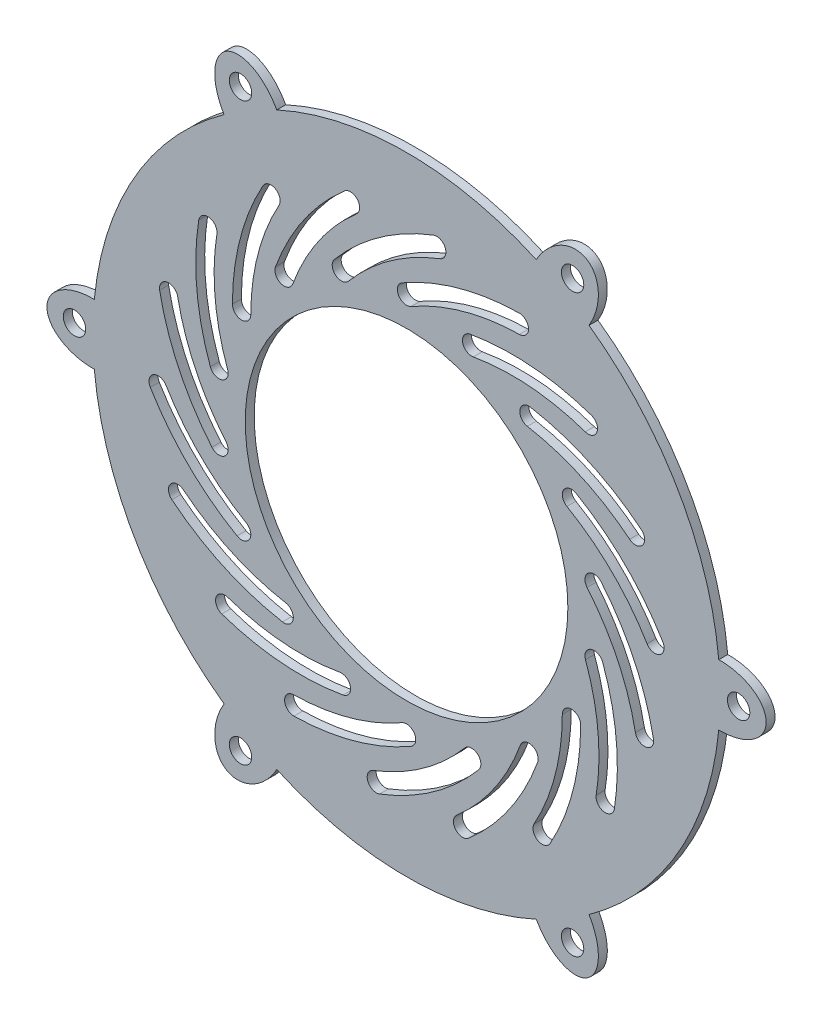
from build123d import *

# Parameters (mm, degrees)
SKETCH1_R           = 36
BOSS_EXTRUDE1_DEPTH = 2
CUT_EXTRUDE3_DEPTH  = 3.0000001
SKETCH6_R           = 2.5
CUT_EXTRUDE4_DEPTH  = 3.0000001
CIRPATTERN1_COUNT   = 6


with BuildPart() as part:
    # Sketch1 → Boss-Extrude1 (new body)
    with BuildSketch(Plane.XY):
        with BuildLine():
            ThreePointArc((-69.673793495, -6.75), (-60.632475945, -34.981464531), (-40.717391873, -56.939388819))
            add(Edge.make_bspline(
                [(-40.717391873, -56.939388819), (-46.197723193, -65.978636893), (-40.119018626, -69.488178611), (-34.04031406, -72.997720328), (-28.952261257, -63.731990147)],
                knots=[1.538524104, 1.538524104, 1.538524104, 3.141592654, 3.141592654, 4.744661203, 4.744661203, 4.744661203], degree=2, weights=[1, 0.695605268, 1, 0.695605268, 1]))
            ThreePointArc((-28.952261257, -63.731990147), (0, -70), (28.952261257, -63.731990147))
            add(Edge.make_bspline(
                [(28.952261257, -63.731990147), (34.04031406, -72.997720328), (40.119018626, -69.488178611), (46.197723193, -65.978636893), (40.717391873, -56.939388819)],
                knots=[1.538524104, 1.538524104, 1.538524104, 3.141592654, 3.141592654, 4.744661203, 4.744661203, 4.744661203], degree=2, weights=[1, 0.695605268, 1, 0.695605268, 1]))
            ThreePointArc((40.717391873, -56.939388819), (60.621778265, -35), (69.66965313, -6.792601328))
            add(Edge.make_bspline(
                [(69.66965313, -6.792601328), (80.238037253, -7.019083435), (80.238037253, 0), (80.238037253, 7.019083435), (69.66965313, 6.792601328)],
                knots=[1.538524104, 1.538524104, 1.538524104, 3.141592654, 3.141592654, 4.744661203, 4.744661203, 4.744661203], degree=2, weights=[1, 0.695605268, 1, 0.695605268, 1]))
            ThreePointArc((69.66965313, 6.792601328), (60.621778265, 35), (40.717391873, 56.939388819))
            add(Edge.make_bspline(
                [(40.717391873, 56.939388819), (46.197723193, 65.978636893), (40.119018626, 69.488178611), (34.04031406, 72.997720328), (28.952261257, 63.731990147)],
                knots=[4.680116758, 4.680116758, 4.680116758, 6.283185307, 6.283185307, 7.886253857, 7.886253857, 7.886253857], degree=2, weights=[1, 0.695605268, 1, 0.695605268, 1]))
            ThreePointArc((28.952261257, 63.731990147), (0, 70), (-28.952261257, 63.731990147))
            add(Edge.make_bspline(
                [(-28.952261257, 63.731990147), (-34.04031406, 72.997720328), (-40.119018626, 69.488178611), (-46.197723193, 65.978636893), (-40.717391873, 56.939388819)],
                knots=[4.680116758, 4.680116758, 4.680116758, 6.283185307, 6.283185307, 7.886253857, 7.886253857, 7.886253857], degree=2, weights=[1, 0.695605268, 1, 0.695605268, 1]))
            ThreePointArc((-40.717391873, 56.939388819), (-60.632475945, 34.981464531), (-69.673793495, 6.75))
            add(Edge.make_bspline(
                [(-69.673793495, 6.75), (-80.25, 6.971880263), (-80.25, 0), (-80.25, -6.971880263), (-69.673793495, -6.75)],
                knots=[1.538965927, 1.538965927, 1.538965927, 3.141592654, 3.141592654, 4.74421938, 4.74421938, 4.74421938], degree=2, weights=[1, 0.69576396, 1, 0.69576396, 1]))
        make_face()
        Circle(SKETCH1_R, mode=Mode.SUBTRACT)
    extrude(amount=BOSS_EXTRUDE1_DEPTH)

    # Sketch2 → Cut-Extrude3 (cut, through all)
    with BuildSketch(Plane.XY):
        with BuildLine():
            ThreePointArc((25.132341942, 51.516012736), (11.592230809, 49.56266401), (-1.025, 44.275352078))
            ThreePointArc((-1.025, 44.275352078), (-1.775352078, 41.475), (1.025, 40.724647922))
            ThreePointArc((1.025, 40.724647922), (12.686026625, 45.611257841), (25.199992553, 47.416570897))
            ThreePointArc((25.199992553, 47.416570897), (27.215888167, 49.500117122), (25.132341942, 51.516012736))
        make_face()
        with BuildLine():
            ThreePointArc((41.236190326, 39.813449827), (27.844563198, 42.608893194), (14.179877327, 41.955792277))
            ThreePointArc((14.179877327, 41.955792277), (12.517000198, 39.580957619), (14.891834856, 37.91808049))
            ThreePointArc((14.891834856, 37.91808049), (27.520934551, 38.521685773), (39.89766942, 35.93809671))
            ThreePointArc((39.89766942, 35.93809671), (42.504606431, 37.206512816), (41.236190326, 39.813449827))
        make_face()
        with BuildLine():
            ThreePointArc((52.366345575, 23.308797286), (40.738430323, 30.515861019), (27.674452176, 34.575744726))
            ThreePointArc((27.674452176, 34.575744726), (25.299617518, 32.912867597), (26.962494647, 30.538032939))
            ThreePointArc((26.962494647, 30.538032939), (39.036411604, 26.785829882), (49.783098528, 20.12495767))
            ThreePointArc((49.783098528, 20.12495767), (52.666641859, 20.425253955), (52.366345575, 23.308797286))
        make_face()
        with BuildLine():
            ThreePointArc((57.180346702, 3.99275979), (48.718641516, 14.742165638), (37.831079661, 23.025352078))
            ThreePointArc((37.831079661, 23.025352078), (35.030727583, 22.275), (35.781079661, 19.474647922))
            ThreePointArc((35.781079661, 19.474647922), (45.843521302, 11.81920759), (53.663951233, 1.884451723))
            ThreePointArc((53.663951233, 1.884451723), (56.476303001, 1.180408022), (57.180346702, 3.99275979))
        make_face()
        with BuildLine():
            ThreePointArc((55.097554126, -15.804863464), (50.822665532, -2.809652489), (43.424720611, 8.697762151))
            ThreePointArc((43.424720611, 8.697762151), (40.536614903, 8.950438659), (40.283938395, 6.062332951))
            ThreePointArc((40.283938395, 6.062332951), (47.121225752, -4.57298557), (51.072139424, -16.583346914))
            ThreePointArc((51.072139424, -16.583346914), (53.4740885, -18.20681254), (55.097554126, -15.804863464))
        make_face()
        with BuildLine():
            ThreePointArc((46.369183368, -33.696186928), (46.796726022, -20.022585061), (43.780699376, -6.678906257))
            ThreePointArc((43.780699376, -6.678906257), (41.153188209, -5.453677678), (39.92795963, -8.081188845))
            ThreePointArc((39.92795963, -8.081188845), (42.715414941, -20.413609181), (42.320273856, -33.050949169))
            ThreePointArc((42.320273856, -33.050949169), (44.022109733, -35.398022805), (46.369183368, -33.696186928))
        make_face()
        with BuildLine():
            ThreePointArc((32.04800476, -47.523252947), (37.126410708, -34.820498372), (38.856079661, -21.25))
            ThreePointArc((38.856079661, -21.25), (36.806079661, -19.2), (34.756079661, -21.25))
            ThreePointArc((34.756079661, -21.25), (33.157494676, -33.792050251), (28.463958681, -45.532119174))
            ThreePointArc((28.463958681, -45.532119174), (29.260414834, -48.3197091), (32.04800476, -47.523252947))
        make_face()
        with BuildLine():
            ThreePointArc((13.8613638, -55.618313291), (22.978102334, -45.418545683), (29.244843284, -33.258030126))
            ThreePointArc((29.244843284, -33.258030126), (28.019614705, -30.63051896), (25.392103539, -31.855747539))
            ThreePointArc((25.392103539, -31.855747539), (19.600291201, -43.094671344), (11.174470005, -52.521443624))
            ThreePointArc((11.174470005, -52.521443624), (10.969482069, -55.413325355), (13.8613638, -55.618313291))
        make_face()
        with BuildLine():
            ThreePointArc((-5.997162206, -57.004984214), (6.058295699, -50.538446079), (16.1062472, -41.254650983))
            ThreePointArc((16.1062472, -41.254650983), (15.853570691, -38.366545275), (12.965464983, -38.619221784))
            ThreePointArc((12.965464983, -38.619221784), (3.679003337, -47.199439063), (-7.462824671, -53.175906839))
            ThreePointArc((-7.462824671, -53.175906839), (-8.644532126, -55.823276759), (-5.997162206, -57.004984214))
        make_face()
        with BuildLine():
            ThreePointArc((-25.132341942, -51.516012736), (-11.592230809, -49.56266401), (1.025, -44.275352078))
            ThreePointArc((1.025, -44.275352078), (1.775352078, -41.475), (-1.025, -40.724647922))
            ThreePointArc((-1.025, -40.724647922), (-12.686026625, -45.611257841), (-25.199992553, -47.416570897))
            ThreePointArc((-25.199992553, -47.416570897), (-27.215888167, -49.500117122), (-25.132341942, -51.516012736))
        make_face()
        with BuildLine():
            ThreePointArc((-41.236190326, -39.813449827), (-27.844563198, -42.608893194), (-14.179877327, -41.955792277))
            ThreePointArc((-14.179877327, -41.955792277), (-12.517000198, -39.580957619), (-14.891834856, -37.91808049))
            ThreePointArc((-14.891834856, -37.91808049), (-27.520934551, -38.521685773), (-39.89766942, -35.93809671))
            ThreePointArc((-39.89766942, -35.93809671), (-42.504606431, -37.206512816), (-41.236190326, -39.813449827))
        make_face()
        with BuildLine():
            ThreePointArc((-52.366345575, -23.308797286), (-40.738430323, -30.515861019), (-27.674452176, -34.575744726))
            ThreePointArc((-27.674452176, -34.575744726), (-25.299617518, -32.912867597), (-26.962494647, -30.538032939))
            ThreePointArc((-26.962494647, -30.538032939), (-39.036411604, -26.785829882), (-49.783098528, -20.12495767))
            ThreePointArc((-49.783098528, -20.12495767), (-52.666641859, -20.425253955), (-52.366345575, -23.308797286))
        make_face()
        with BuildLine():
            ThreePointArc((-57.180346702, -3.99275979), (-48.718641516, -14.742165638), (-37.831079661, -23.025352078))
            ThreePointArc((-37.831079661, -23.025352078), (-35.030727583, -22.275), (-35.781079661, -19.474647922))
            ThreePointArc((-35.781079661, -19.474647922), (-45.843521302, -11.81920759), (-53.663951233, -1.884451723))
            ThreePointArc((-53.663951233, -1.884451723), (-56.476303001, -1.180408022), (-57.180346702, -3.99275979))
        make_face()
        with BuildLine():
            ThreePointArc((-55.097554126, 15.804863464), (-50.822665532, 2.809652489), (-43.424720611, -8.697762151))
            ThreePointArc((-43.424720611, -8.697762151), (-40.536614903, -8.950438659), (-40.283938395, -6.062332951))
            ThreePointArc((-40.283938395, -6.062332951), (-47.121225752, 4.57298557), (-51.072139424, 16.583346914))
            ThreePointArc((-51.072139424, 16.583346914), (-53.4740885, 18.20681254), (-55.097554126, 15.804863464))
        make_face()
        with BuildLine():
            ThreePointArc((-46.369183368, 33.696186928), (-46.796726022, 20.022585061), (-43.780699376, 6.678906257))
            ThreePointArc((-43.780699376, 6.678906257), (-41.153188209, 5.453677678), (-39.92795963, 8.081188845))
            ThreePointArc((-39.92795963, 8.081188845), (-42.715414941, 20.413609181), (-42.320273856, 33.050949169))
            ThreePointArc((-42.320273856, 33.050949169), (-44.022109733, 35.398022805), (-46.369183368, 33.696186928))
        make_face()
        with BuildLine():
            ThreePointArc((-32.04800476, 47.523252947), (-37.126410708, 34.820498372), (-38.856079661, 21.25))
            ThreePointArc((-38.856079661, 21.25), (-36.806079661, 19.2), (-34.756079661, 21.25))
            ThreePointArc((-34.756079661, 21.25), (-33.157494676, 33.792050251), (-28.463958681, 45.532119174))
            ThreePointArc((-28.463958681, 45.532119174), (-29.260414834, 48.3197091), (-32.04800476, 47.523252947))
        make_face()
        with BuildLine():
            ThreePointArc((-13.8613638, 55.618313291), (-22.978102334, 45.418545683), (-29.244843284, 33.258030126))
            ThreePointArc((-29.244843284, 33.258030126), (-28.019614705, 30.63051896), (-25.392103539, 31.855747539))
            ThreePointArc((-25.392103539, 31.855747539), (-19.600291201, 43.094671344), (-11.174470005, 52.521443624))
            ThreePointArc((-11.174470005, 52.521443624), (-10.969482069, 55.413325355), (-13.8613638, 55.618313291))
        make_face()
        with BuildLine():
            ThreePointArc((5.997162206, 57.004984214), (-6.058295699, 50.538446079), (-16.1062472, 41.254650983))
            ThreePointArc((-16.1062472, 41.254650983), (-15.853570691, 38.366545275), (-12.965464983, 38.619221784))
            ThreePointArc((-12.965464983, 38.619221784), (-3.679003337, 47.199439063), (7.462824671, 53.175906839))
            ThreePointArc((7.462824671, 53.175906839), (8.644532126, 55.823276759), (5.997162206, 57.004984214))
        make_face()
    extrude(amount=CUT_EXTRUDE3_DEPTH, mode=Mode.SUBTRACT)

    # Sketch6 → Cut-Extrude4 (cut, through all)
    with BuildSketch(Plane.XY):
        with Locations((-74.098892388, 0)):
            Circle(SKETCH6_R)
    cut_extrude4 = extrude(amount=CUT_EXTRUDE4_DEPTH, mode=Mode.SUBTRACT)

    # CirPattern1: Cut-Extrude4 ×6 about axis
    cirpattern1_axis = Axis((0, 0, 0), (0, 0, 1))
    for i in range(1, CIRPATTERN1_COUNT):
        add(cut_extrude4.rotate(cirpattern1_axis, i * 360 / CIRPATTERN1_COUNT), mode=Mode.SUBTRACT)


solid = part.part
